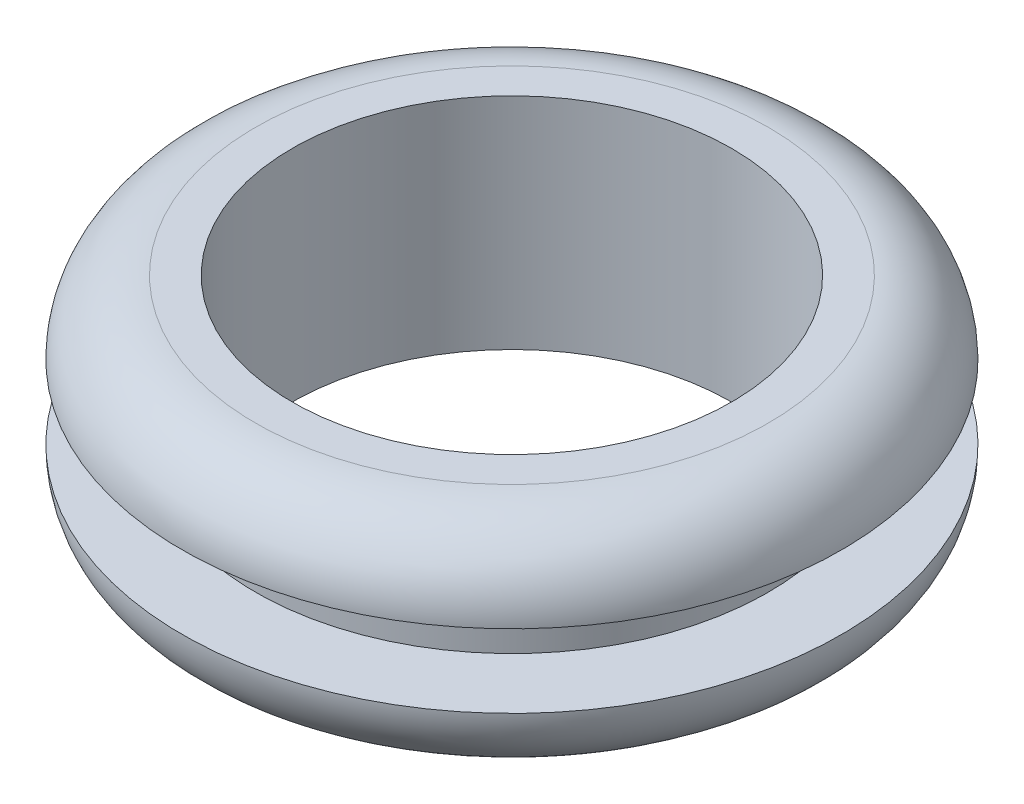
from build123d import *


with BuildPart() as part:
    # Sketch2 → Revolve1 (revolve)
    with BuildSketch(Plane(origin=(0, 0, 0), x_dir=(0, 0, -1), z_dir=(1, 0, 0))):
        with BuildLine():
            Line((-9.525, -4.7625), (-9.525, 4.7625))
            Line((-9.525, 4.7625), (-11.1125, 4.7625))
            ThreePointArc((-11.1125, 4.7625), (-13.35756403, 3.83256403), (-14.2875, 1.5875))
            Line((-14.2875, 1.5875), (-11.1125, 1.5875))
            Line((-11.1125, 1.5875), (-11.1125, -1.5875))
            Line((-11.1125, -1.5875), (-14.2875, -1.5875))
            ThreePointArc((-14.2875, -1.5875), (-13.35756403, -3.83256403), (-11.1125, -4.7625))
            Line((-11.1125, -4.7625), (-9.525, -4.7625))
        make_face()
    revolve(axis=Axis((0, -4.7625, 0), (0, 1, 0)))


solid = part.part
